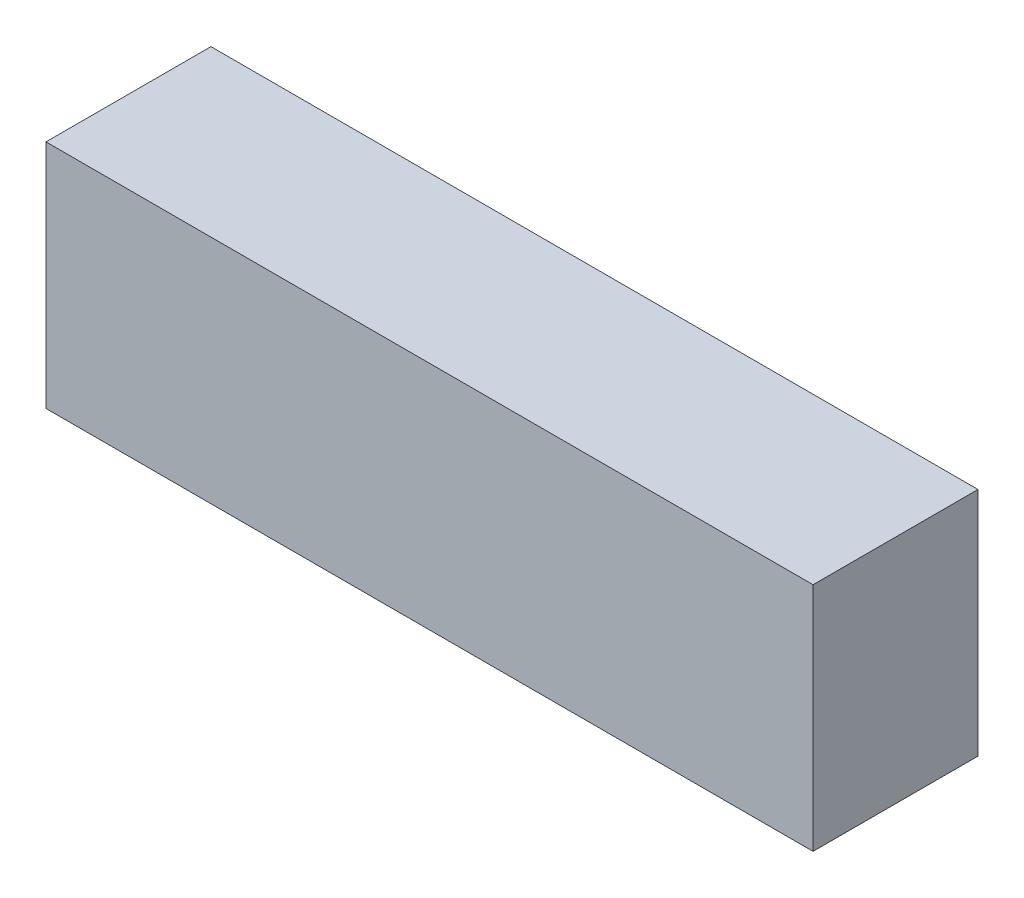
from build123d import *

# Parameters (mm, degrees)
SKETCH_1_W      = 93
SKETCH_1_H      = 28
EXTRUDE_1_DEPTH = 20


with BuildPart() as part:
    # 草图1 → 凸台-拉伸1 (new body)
    with BuildSketch(Plane.XY):
        Rectangle(SKETCH_1_W, SKETCH_1_H)
    extrude(amount=EXTRUDE_1_DEPTH)


solid = part.part
